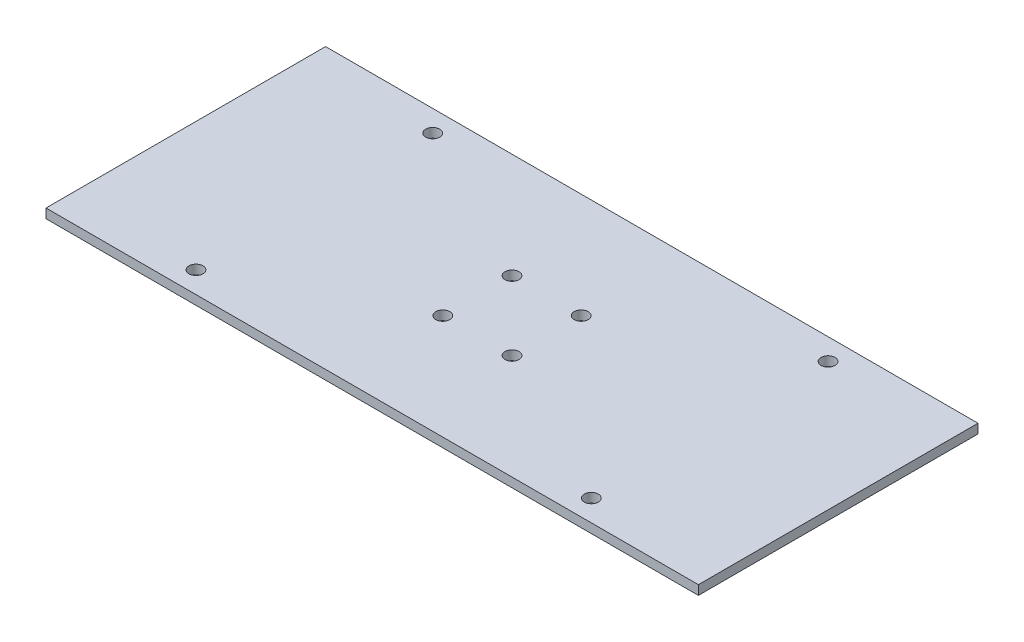
from build123d import *

# Parameters (mm, degrees)
SKETCH_1_W      = 140
SKETCH_1_H      = 60
SKETCH_1_R      = 1.5
EXTRUDE_1_DEPTH = 2


with BuildPart() as part:
    # 草图1 → 凸台-拉伸1 (new body)
    with BuildSketch(Plane(origin=(0, 0, 0), x_dir=(1, 0, 0), z_dir=(0, 1, 0))):
        Rectangle(SKETCH_1_W, SKETCH_1_H)
        with Locations((-42.42, 25.4)):
            Circle(SKETCH_1_R, mode=Mode.SUBTRACT)
        with Locations((-42.42, -25.4)):
            Circle(SKETCH_1_R, mode=Mode.SUBTRACT)
        with Locations((42.42, -25.4)):
            Circle(SKETCH_1_R, mode=Mode.SUBTRACT)
        with Locations((42.42, 25.4)):
            Circle(SKETCH_1_R, mode=Mode.SUBTRACT)
        with Locations((-7.425, 7.425)):
            Circle(SKETCH_1_R, mode=Mode.SUBTRACT)
        with Locations((7.425, 7.425)):
            Circle(SKETCH_1_R, mode=Mode.SUBTRACT)
        with Locations((7.425, -7.425)):
            Circle(SKETCH_1_R, mode=Mode.SUBTRACT)
        with Locations((-7.425, -7.425)):
            Circle(SKETCH_1_R, mode=Mode.SUBTRACT)
    extrude(amount=EXTRUDE_1_DEPTH)


solid = part.part
